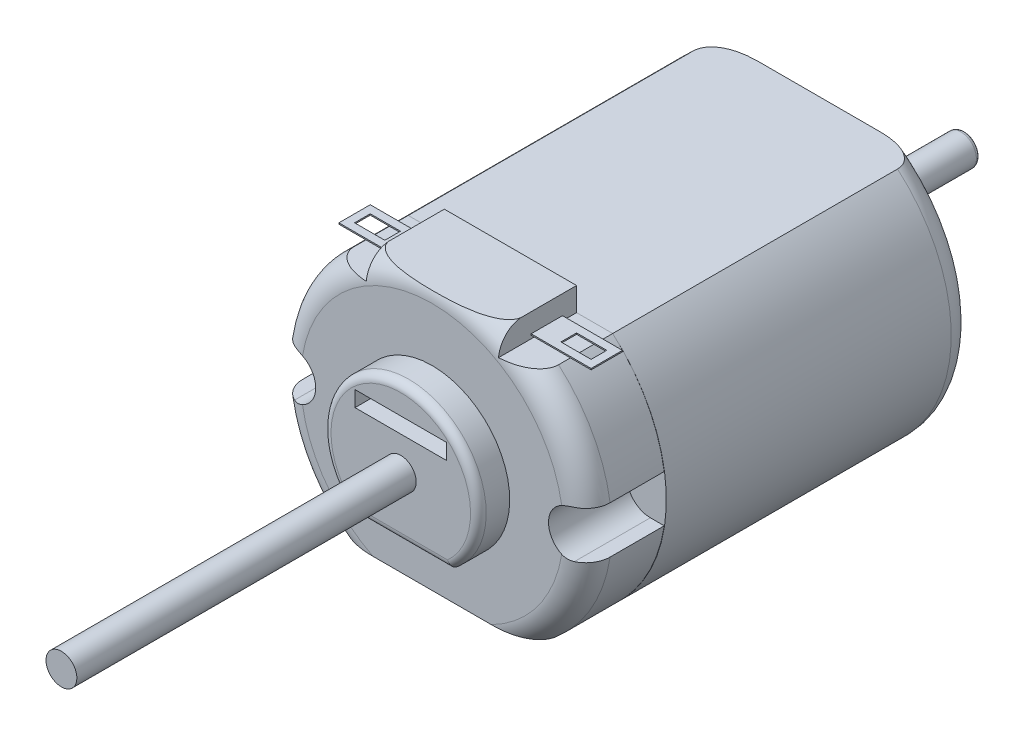
from build123d import *

# Parameters (mm, degrees)
EXTRUDE1_DEPTH          = 5
EXTRUDE2_DEPTH          = 2
SKETCH5_R               = 0.985
EXTRUDE3_DEPTH          = 25
FILLET1_R               = 0.25
FILLET2_R               = 0.5
CUT_EXTRUDE2_DEPTH      = 6
SKETCH7_W               = 8.44
SKETCH7_H               = 5
EXTRUDE4_DEPTH          = 1.5
SKETCH9_W               = 2
SKETCH9_H               = 0.08
EXTRUDE5_DEPTH          = 3.83
CUT_EXTRUDE4_REACH      = 17.25
SKETCH10_W              = 1.93
SKETCH10_H              = 1
SKETCH21_W              = 2
SKETCH21_H              = 0.08
EXTRUDE6_DEPTH          = 3.83
SKETCH22_W              = 1.93
SKETCH22_H              = 1
CUT_EXTRUDE5_DEPTH      = 0.09
EXTRUDE7_DEPTH          = 19.685
FILLET6_R               = 1.5
SKETCH26_R              = 3.048
EXTRUDE9_DEPTH          = 1.6002
SKETCH27_R              = 2.54
CUT_EXTRUDE6_DEPTH      = 0.5334
CHAMFER1_SIZE           = 0.4
CHAMFER1_SIZE2          = 0.145588094
SKETCH29_R              = 0.985
EXTRUDE10_DEPTH         = 8.255
FILLET7_R               = 0.25
SKETCH30_R              = 0.73025
CUT_EXTRUDE7_DEPTH      = 8.255
CUT_EXTRUDE9_DEPTH      = 2
CUT_EXTRUDE9_DEPTH_BACK = 5
SKETCH31_R              = 2.701313407
CUT_EXTRUDE10_DEPTH     = 2.275338
SKETCH32_R              = 2.019963582
CUT_EXTRUDE11_DEPTH     = 1.063418


with BuildPart() as part:
    # Sketch1 → Extrude1 (new body)
    with BuildSketch(Plane.XY):
        with BuildLine():
            Line((-6.525310337, -7.485), (6.525310337, -7.485))
            ThreePointArc((6.525310337, -7.485), (9.93, 0), (6.525310337, 7.485))
            Line((6.525310337, 7.485), (-6.525310337, 7.485))
            ThreePointArc((-6.525310337, 7.485), (-9.93, 0), (-6.525310337, -7.485))
        make_face()
    extrude(amount=EXTRUDE1_DEPTH)

    # Sketch2 → Extrude2 (add)
    with BuildSketch(Plane.XY.offset(5)):
        with BuildLine():
            Line((-3.175, -3.801523905), (3.175, -3.801523905))
            ThreePointArc((3.175, -3.801523905), (0, 4.953), (-3.175, -3.801523905))
        make_face()
    extrude(amount=EXTRUDE2_DEPTH)

    # Sketch5 → Extrude3 (add)
    with BuildSketch(Plane.XY.offset(7)):
        Circle(SKETCH5_R)
    extrude(amount=EXTRUDE3_DEPTH)

    # Fillet1
    fillet1_edges = [part.edges().sort_by_distance(p)[0] for p in [
        (-0.985, 0, 32),
    ]]
    fillet(fillet1_edges, radius=FILLET1_R)

    # Fillet2
    fillet2_edges = [part.edges().sort_by_distance(p)[0] for p in [
        (0, 4.953, 7),
        (0, -3.801523905, 7),
    ]]
    fillet(fillet2_edges, radius=FILLET2_R)

    # Sketch6 → Cut-Extrude2 (cut, through all)
    with BuildSketch(Plane.XY.offset(5)):
        with BuildLine():
            Line((8.93, 1.5), (9.816053178, 1.5))
            ThreePointArc((9.816053178, 1.5), (9.93, 0), (9.816053178, -1.5))
            Line((9.816053178, -1.5), (8.93, -1.5))
            ThreePointArc((8.93, -1.5), (7.43, 0), (8.93, 1.5))
        make_face()
    cut_extrude2 = extrude(amount=-CUT_EXTRUDE2_DEPTH, mode=Mode.SUBTRACT)

    # Mirror1: Cut-Extrude2 across plane
    add(cut_extrude2.mirror(Plane(origin=(0, 0, 0), x_dir=(0, 0, 1), z_dir=(1, 0, 0))), mode=Mode.SUBTRACT)

    # Sketch7 → Extrude4 (add)
    with BuildSketch(Plane(origin=(0, 7.485, 0), x_dir=(-1, 0, 0), z_dir=(0, 1, 0))):
        with Locations((0, 2.5)):
            Rectangle(SKETCH7_W, SKETCH7_H)
    extrude(amount=EXTRUDE4_DEPTH)

    # Sketch8 → Cut-Revolve1 (revolve, cut)
    with BuildSketch(Plane(origin=(0, 0, 0), x_dir=(-0.988524993, -0.151057402, 0), z_dir=(-0.151057402, 0.988524993, 0))):
        with BuildLine():
            Line((9.93, 3.453506144), (12.335658501, 3.453506144))
            Line((12.335658501, 3.453506144), (12.335658501, 5.727879127))
            Line((12.335658501, 5.727879127), (8.383506144, 5.727879127))
            Line((8.383506144, 5.727879127), (8.383506144, 5))
            ThreePointArc((8.383506144, 5), (9.477042437, 4.547042437), (9.93, 3.453506144))
        make_face()
    revolve(axis=Axis((0, 0, 0), (0, 0, 1)), mode=Mode.SUBTRACT)

    # Sketch9 → Extrude5 (add)
    with BuildSketch(Plane(origin=(4.22, 0, 0), x_dir=(0, 0, -1), z_dir=(1, 0, 0))):
        with Locations((-1.9, 7.725)):
            Rectangle(SKETCH9_W, SKETCH9_H)
    extrude(amount=EXTRUDE5_DEPTH)

    # Sketch10 → Cut-Extrude4 (cut, up to next)
    with BuildSketch(Plane(origin=(0, 7.765, 0), x_dir=(-1, 0, 0), z_dir=(0, 1, 0)), mode=Mode.PRIVATE) as cut_extrude4_sk1:
        with Locations((-6.585, 1.9)):
            Rectangle(SKETCH10_W, SKETCH10_H)
    cut_extrude4_tool1 = extrude(cut_extrude4_sk1.sketch, amount=-CUT_EXTRUDE4_REACH, mode=Mode.PRIVATE) & part.part
    add(cut_extrude4_tool1.solids().sort_by_distance((6.585, 7.765, 1.9))[0], mode=Mode.SUBTRACT)

    # Sketch21 → Extrude6 (add)
    with BuildSketch(Plane.ZY.offset(4.22)):
        with Locations((1.9, 7.725)):
            Rectangle(SKETCH21_W, SKETCH21_H)
    extrude(amount=EXTRUDE6_DEPTH)

    # Sketch22 → Cut-Extrude5 (cut)
    with BuildSketch(Plane(origin=(0, 7.765, 0), x_dir=(-1, 0, 0), z_dir=(0, 1, 0))):
        with Locations((6.585, 1.9)):
            Rectangle(SKETCH22_W, SKETCH22_H)
    extrude(amount=-CUT_EXTRUDE5_DEPTH, mode=Mode.SUBTRACT)

    # Sketch4 → Cut-Extrude9 (cut, two sides)
    with BuildSketch(Plane.XY.offset(5)) as cut_extrude9_sk:
        Polygon((-2.921, 3.161292816), (2.92099995, 3.16205781), (2.921, 2.16205781), (-2.921, 2.16205781), align=None)
    extrude(amount=CUT_EXTRUDE9_DEPTH, mode=Mode.SUBTRACT)
    extrude(cut_extrude9_sk.sketch, amount=-CUT_EXTRUDE9_DEPTH_BACK, mode=Mode.SUBTRACT)

    # Sketch31 → Cut-Extrude10 (cut)
    with BuildSketch(Plane.XY.offset(32)):
        Circle(SKETCH31_R)
    extrude(amount=-CUT_EXTRUDE10_DEPTH, mode=Mode.SUBTRACT)

    # Sketch32 → Cut-Extrude11 (cut)
    with BuildSketch(Plane.XY.offset(29.724661786)):
        Circle(SKETCH32_R)
    extrude(amount=-CUT_EXTRUDE11_DEPTH, mode=Mode.SUBTRACT)


with BuildPart() as body_2:
    # Sketch23 → Extrude7 (new body)
    with BuildSketch(Plane(origin=(0, 0, 0), x_dir=(-1, 0, 0), z_dir=(0, 0, -1))):
        with BuildLine():
            Line((-6.525310337, 7.485), (6.525310337, 7.485))
            ThreePointArc((6.525310337, 7.485), (9.926356983, 0), (6.525310337, -7.485))
            Line((6.525310337, -7.485), (-6.525310337, -7.485))
            ThreePointArc((-6.525310337, -7.485), (-9.950448891, 0), (-6.525310337, 7.485))
        make_face()
    extrude(amount=EXTRUDE7_DEPTH)

    # Fillet6
    fillet6_edges = [body_2.edges().sort_by_distance(p)[0] for p in [
        (9.950448891, 0, -19.685),
        (-9.926356983, 0, -19.685),
    ]]
    fillet(fillet6_edges, radius=FILLET6_R)

    # Sketch26 → Extrude9 (add)
    with BuildSketch(Plane(origin=(0, 0, -19.685), x_dir=(-1, 0, 0), z_dir=(0, 0, -1))):
        Circle(SKETCH26_R)
    extrude(amount=EXTRUDE9_DEPTH)

    # Sketch27 → Cut-Extrude6 (cut)
    with BuildSketch(Plane(origin=(0, 0, -21.2852), x_dir=(-1, 0, 0), z_dir=(0, 0, -1))):
        Circle(SKETCH27_R)
    extrude(amount=-CUT_EXTRUDE6_DEPTH, mode=Mode.SUBTRACT)

    # Chamfer1
    chamfer1_edges = [body_2.edges().sort_by_distance(p)[0] for p in [
        (3.048, 0, -21.2852),
    ]]
    chamfer1_side = [body_2.faces().sort_by_distance(p)[0] for p in [
        (3.048, 0, -20.4851),
    ]]
    chamfer(chamfer1_edges, length=CHAMFER1_SIZE, length2=CHAMFER1_SIZE2, reference=chamfer1_side[0])

    # Sketch29 → Extrude10 (add)
    with BuildSketch(Plane(origin=(0, 0, -20.7518), x_dir=(-1, 0, 0), z_dir=(0, 0, -1))):
        Circle(SKETCH29_R)
    extrude(amount=EXTRUDE10_DEPTH)

    # Fillet7
    fillet7_edges = [body_2.edges().sort_by_distance(p)[0] for p in [
        (0.985, 0, -29.0068),
    ]]
    fillet(fillet7_edges, radius=FILLET7_R)

    # Sketch30 → Cut-Extrude7 (cut)
    with BuildSketch(Plane(origin=(0, 0, -19.685), x_dir=(-1, 0, 0), z_dir=(0, 0, -1))):
        with Locations((0, -5.199)):
            Circle(SKETCH30_R)
    extrude(amount=-CUT_EXTRUDE7_DEPTH, mode=Mode.SUBTRACT)


solid = Compound([part.part, body_2.part])
